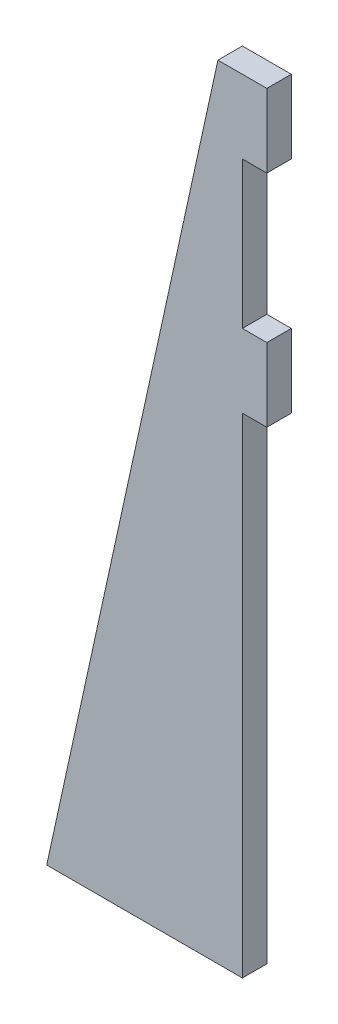
from build123d import *

# Parameters (mm, degrees)
SKETCH1_W           = 3.175
SKETCH1_H           = 9.525
BOSS_EXTRUDE1_DEPTH = 3.175


with BuildPart() as part:
    # Sketch1 → Boss-Extrude1 (new body)
    with BuildSketch(Plane.XY):
        Polygon((0, 101.6), (-3.175, 101.6), (-25.4, 0), (0, 0), align=None)
        with Locations((1.5875, 68.2625)):
            Rectangle(SKETCH1_W, SKETCH1_H)
        with Locations((1.5875, 96.8375)):
            Rectangle(SKETCH1_W, SKETCH1_H)
    extrude(amount=BOSS_EXTRUDE1_DEPTH)


solid = part.part
